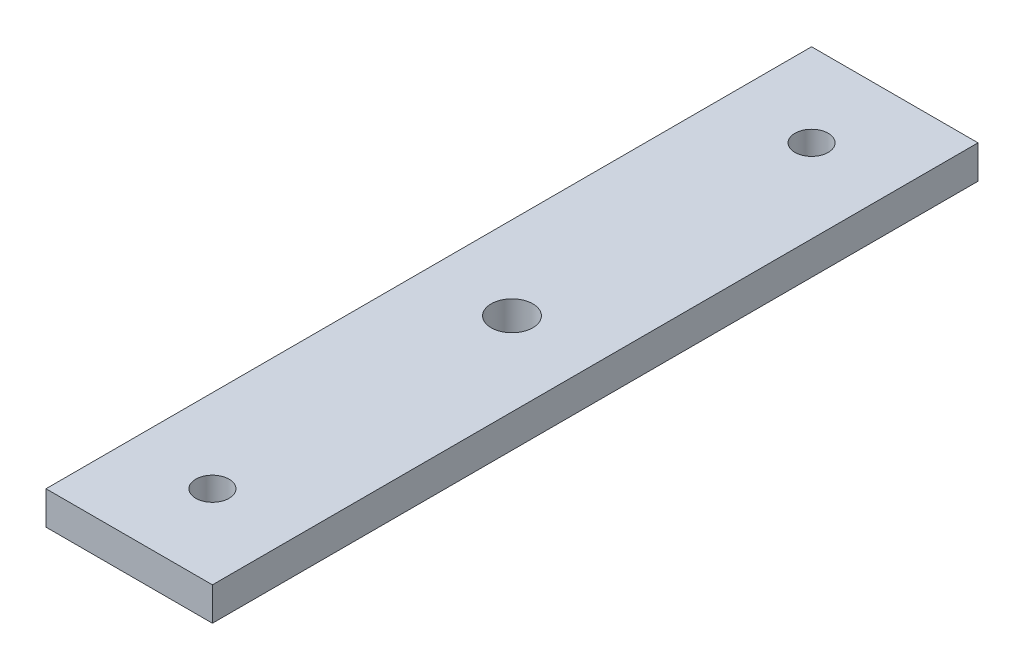
from build123d import *

# Parameters (mm, degrees)
SKETCH1_W           = 100
SKETCH1_H           = 460
SKETCH1_R           = 10
BOSS_EXTRUDE1_DEPTH = 20
SKETCH2_R           = 12.5
CUT_EXTRUDE1_DEPTH  = 21


with BuildPart() as part:
    # Sketch1 → Boss-Extrude1 (new body)
    with BuildSketch(Plane(origin=(0, 0, 0), x_dir=(1, 0, 0), z_dir=(0, 1, 0))):
        Rectangle(SKETCH1_W, SKETCH1_H)
        with Locations((0, -180)):
            Circle(SKETCH1_R, mode=Mode.SUBTRACT)
        with Locations((0, 180)):
            Circle(SKETCH1_R, mode=Mode.SUBTRACT)
    extrude(amount=BOSS_EXTRUDE1_DEPTH)

    # Sketch2 → Cut-Extrude1 (cut, through all)
    with BuildSketch(Plane(origin=(0, 20, 0), x_dir=(1, 0, 0), z_dir=(0, 1, 0))):
        Circle(SKETCH2_R)
    extrude(amount=-CUT_EXTRUDE1_DEPTH, mode=Mode.SUBTRACT)


solid = part.part
